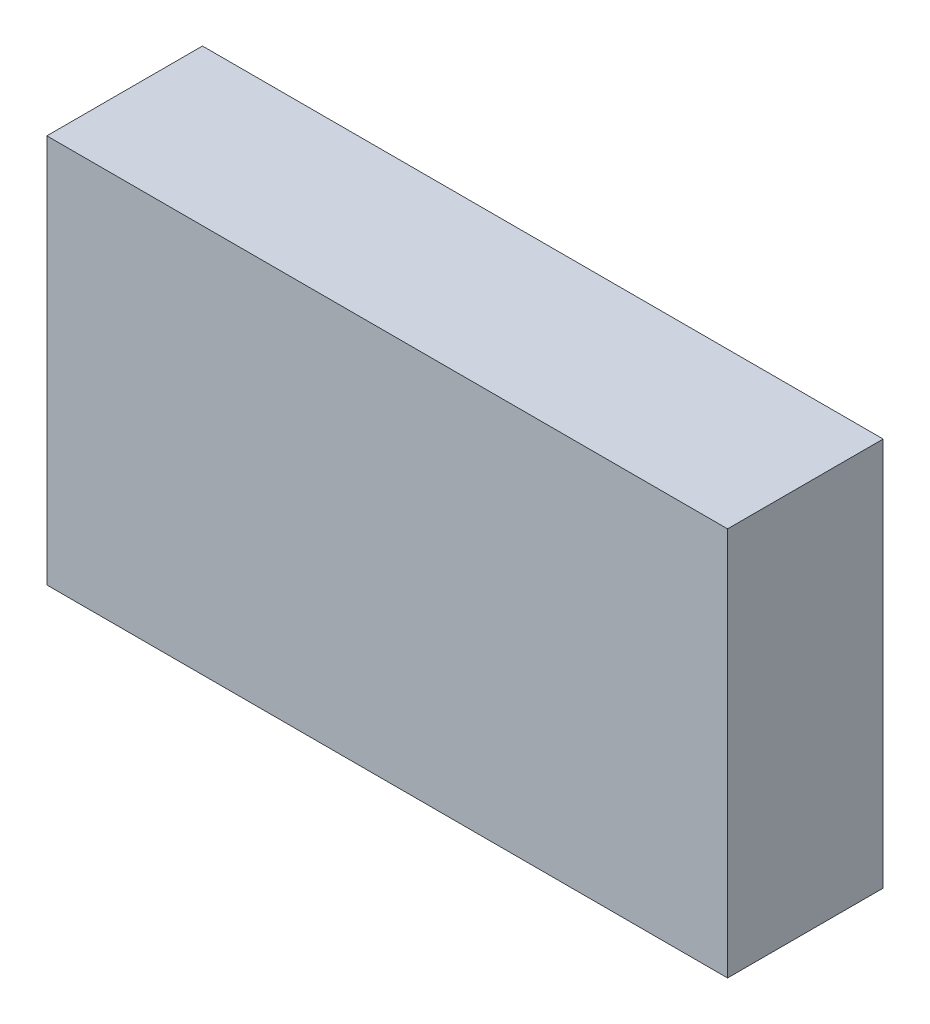
from build123d import *

# Parameters (mm, degrees)
ESBO_O1_W                = 35
ESBO_O1_H                = 20
RESSALTO_EXTRUS_O1_DEPTH = 8


with BuildPart() as part:
    # Esboço1 → Ressalto-extrusão1 (new body)
    with BuildSketch(Plane.XY):
        Rectangle(ESBO_O1_W, ESBO_O1_H)
    extrude(amount=RESSALTO_EXTRUS_O1_DEPTH)


solid = part.part
